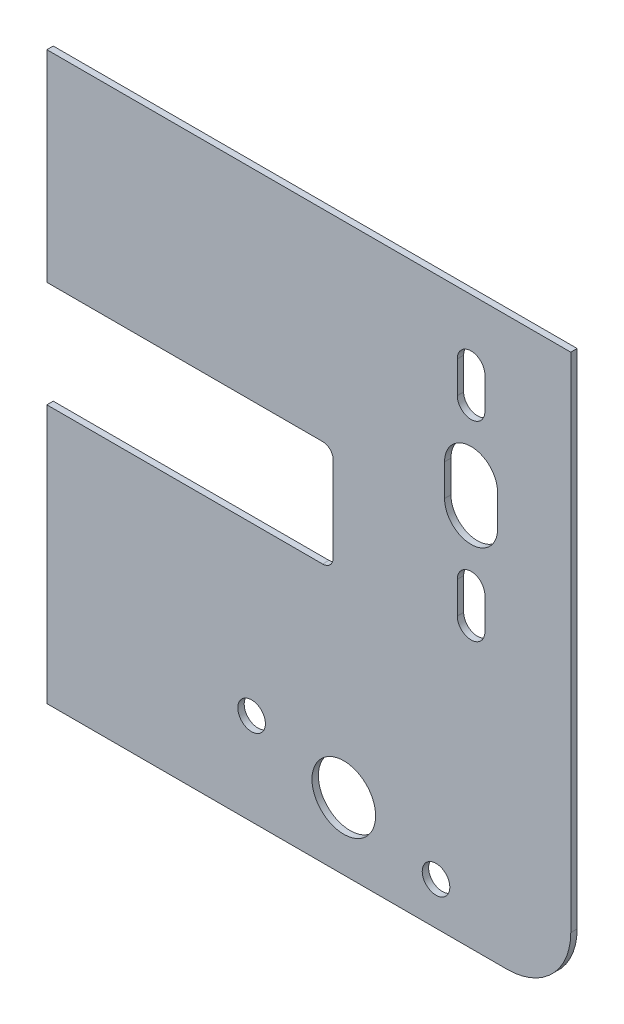
from build123d import *

# Parameters (mm, degrees)
ESQUISSE1_W             = 247
ESQUISSE1_H             = 267
ESQUISSE1_R             = 12.5
ESQUISSE1_R_2           = 6.5
BOSS_EXTRU_1_DEPTH      = 3
ESQUISSE3_R             = 6.5
ESQUISSE3_R_2           = 15
ENL_V_MAT_EXTRU_2_DEPTH = 3
ESQUISSE4_W             = 135
ESQUISSE4_H             = 50
ENL_V_MAT_EXTRU_3_DEPTH = 10
CONG_1_R                = 5
CONG_2_R                = 30
ENL_V_MAT_EXTRU_4_DEPTH = 10


with BuildPart() as part:
    # Esquisse1 → Boss.-Extru.1 (new body)
    with BuildSketch(Plane.XY):
        Rectangle(ESQUISSE1_W, ESQUISSE1_H)
        with Locations((76.5, 51.5)):
            Circle(ESQUISSE1_R, mode=Mode.SUBTRACT)
        with Locations((76.5, 96.5)):
            Circle(ESQUISSE1_R_2, mode=Mode.SUBTRACT)
        with Locations((76.5, 6.5)):
            Circle(ESQUISSE1_R_2, mode=Mode.SUBTRACT)
    extrude(amount=BOSS_EXTRU_1_DEPTH)

    # Esquisse3 → Enlèv. mat.-Extru.2 (cut)
    with BuildSketch(Plane(origin=(0, 0, 0), x_dir=(-1, 0, 0), z_dir=(0, 0, -1))):
        with Locations((-59.966662183, -113.5)):
            Circle(ESQUISSE3_R)
        with Locations((-16.5, -101.85314297)):
            Circle(ESQUISSE3_R_2)
        with Locations((26.966662183, -90.206285941)):
            Circle(ESQUISSE3_R)
    extrude(amount=-ENL_V_MAT_EXTRU_2_DEPTH, mode=Mode.SUBTRACT)

    # Esquisse4 → Enlèv. mat.-Extru.3 (cut)
    with BuildSketch(Plane(origin=(0, 0, 0), x_dir=(-1, 0, 0), z_dir=(0, 0, -1))):
        with Locations((56, 13.5)):
            Rectangle(ESQUISSE4_W, ESQUISSE4_H)
    extrude(amount=-ENL_V_MAT_EXTRU_3_DEPTH, mode=Mode.SUBTRACT)

    # Congé1
    cong_1_edges = [part.edges().sort_by_distance(p)[0] for p in [
        (11.5, -11.5, 1.5),
        (11.5, 38.5, 1.5),
    ]]
    fillet(cong_1_edges, radius=CONG_1_R)

    # Congé2
    cong_2_edges = [part.edges().sort_by_distance(p)[0] for p in [
        (123.5, -133.5, 1.5),
    ]]
    fillet(cong_2_edges, radius=CONG_2_R)

    # Esquisse5 → Enlèv. mat.-Extru.4 (cut)
    with BuildSketch(Plane(origin=(0, 0, 0), x_dir=(-1, 0, 0), z_dir=(0, 0, -1))):
        with BuildLine():
            Line((-83, 89), (-83, 104))
            ThreePointArc((-83, 104), (-76.5, 110.5), (-70, 104))
            Line((-70, 104), (-70, 89))
            ThreePointArc((-70, 89), (-76.5, 82.5), (-83, 89))
        make_face()
        with BuildLine():
            Line((-83, -1), (-83, 14))
            ThreePointArc((-83, 14), (-76.5, 20.5), (-70, 14))
            Line((-70, 14), (-70, -1))
            ThreePointArc((-70, -1), (-76.5, -7.5), (-83, -1))
        make_face()
        with BuildLine():
            Line((-89, 44), (-89, 59))
            ThreePointArc((-89, 59), (-76.5, 71.5), (-64, 59))
            Line((-64, 59), (-64, 44))
            ThreePointArc((-64, 44), (-76.5, 31.5), (-89, 44))
        make_face()
    extrude(amount=-ENL_V_MAT_EXTRU_4_DEPTH, mode=Mode.SUBTRACT)


solid = part.part
